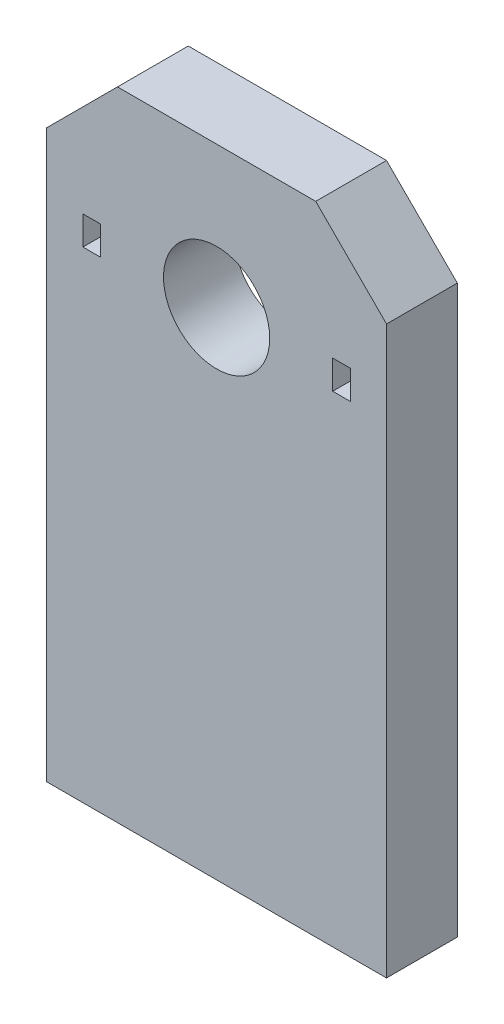
from build123d import *

# Parameters (mm, degrees)
SKETCH1_W           = 30.48
SKETCH1_H           = 57.15
SKETCH1_R           = 4.7625
SKETCH1_W_2         = 1.5748
SKETCH1_H_2         = 2.5781
BOSS_EXTRUDE1_DEPTH = 6.35
CHAMFER1_SIZE       = 6.35


with BuildPart() as part:
    # Sketch1 → Boss-Extrude1 (new body)
    with BuildSketch(Plane.XY):
        with Locations((0, 28.575)):
            Rectangle(SKETCH1_W, SKETCH1_H)
        with Locations((0, 44.45)):
            Circle(SKETCH1_R, mode=Mode.SUBTRACT)
        with Locations((-11.2014, 44.45)):
            Rectangle(SKETCH1_W_2, SKETCH1_H_2, mode=Mode.SUBTRACT)
        with Locations((11.2014, 44.45)):
            Rectangle(SKETCH1_W_2, SKETCH1_H_2, mode=Mode.SUBTRACT)
    extrude(amount=BOSS_EXTRUDE1_DEPTH)

    # Chamfer1
    chamfer1_edges = [part.edges().sort_by_distance(p)[0] for p in [
        (15.24, 57.15, 3.175),
        (-15.24, 57.15, 3.175),
    ]]
    chamfer(chamfer1_edges, length=CHAMFER1_SIZE)


solid = part.part
